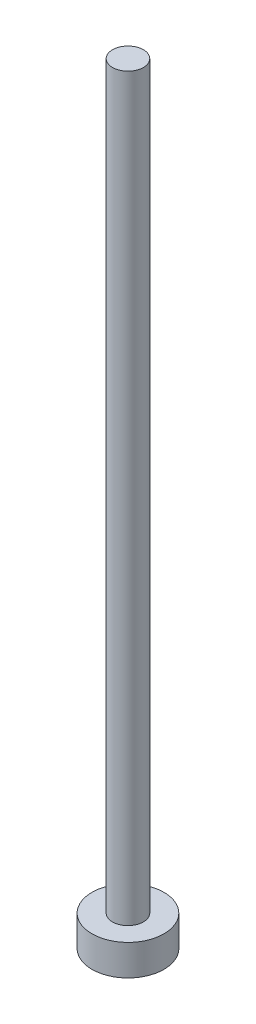
from build123d import *

# Parameters (mm, degrees)
CUT_EXTRUDE_1_DEPTH = 2
SCALE_1_SCALE       = 0.58


with BuildPart() as part:
    # 草图1 → 旋转1 (revolve)
    with BuildSketch(Plane.XY):
        Polygon((1.5, 70), (1.5, 72), (0, 72), (0, 70), (0, -3), (3.5, -3), (3.5, 0), (1.5, 0), align=None)
    revolve(axis=Axis((0, 78.762815816, 0), (0, -1, 0)))

    # 草图2 → 切除-拉伸1 (cut)
    with BuildSketch(Plane.XZ.offset(3)):
        Polygon((2.503979876, 0), (1.251989938, 2.168510183), (-1.251989938, 2.168510183), (-2.503979876, 0), (-1.251989938, -2.168510183), (1.251989938, -2.168510183), align=None)
    extrude(amount=-CUT_EXTRUDE_1_DEPTH, mode=Mode.SUBTRACT)


with BuildPart() as part_1:
    # 缩放比例1: scaled about (0, 30.776232498, 0)
    add(part.part.scale(SCALE_1_SCALE).moved(Location((0, 12.926017649, 0))))


solid = part_1.part
